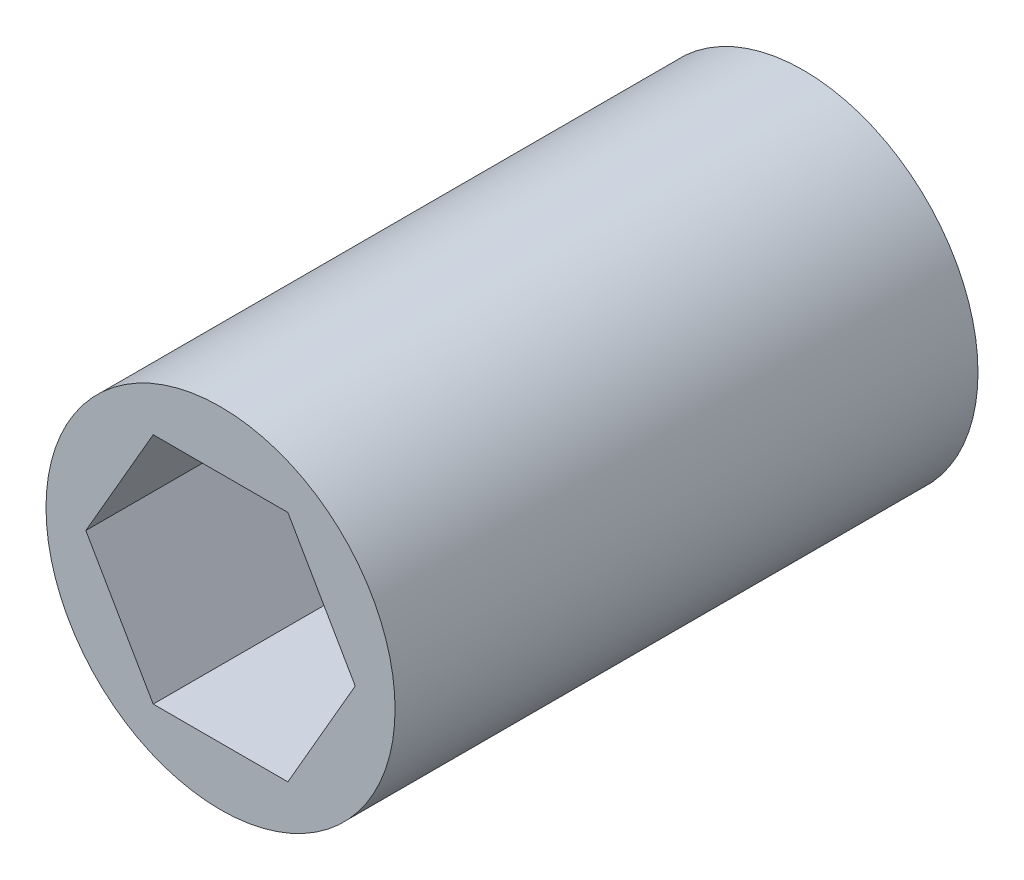
from build123d import *

# Parameters (mm, degrees)
SKETCH1_R           = 7.5
BOSS_EXTRUDE1_DEPTH = 12.525


with BuildPart() as part:
    # Sketch1 → Boss-Extrude1 (new, symmetric)
    with BuildSketch(Plane.XY):
        Circle(SKETCH1_R)
        Polygon((5.787936449, 0), (2.893968224, 5.0125), (-2.893968224, 5.0125), (-5.787936449, 0), (-2.893968224, -5.0125), (2.893968224, -5.0125), align=None, mode=Mode.SUBTRACT)
    extrude(amount=BOSS_EXTRUDE1_DEPTH, both=True)


solid = part.part
